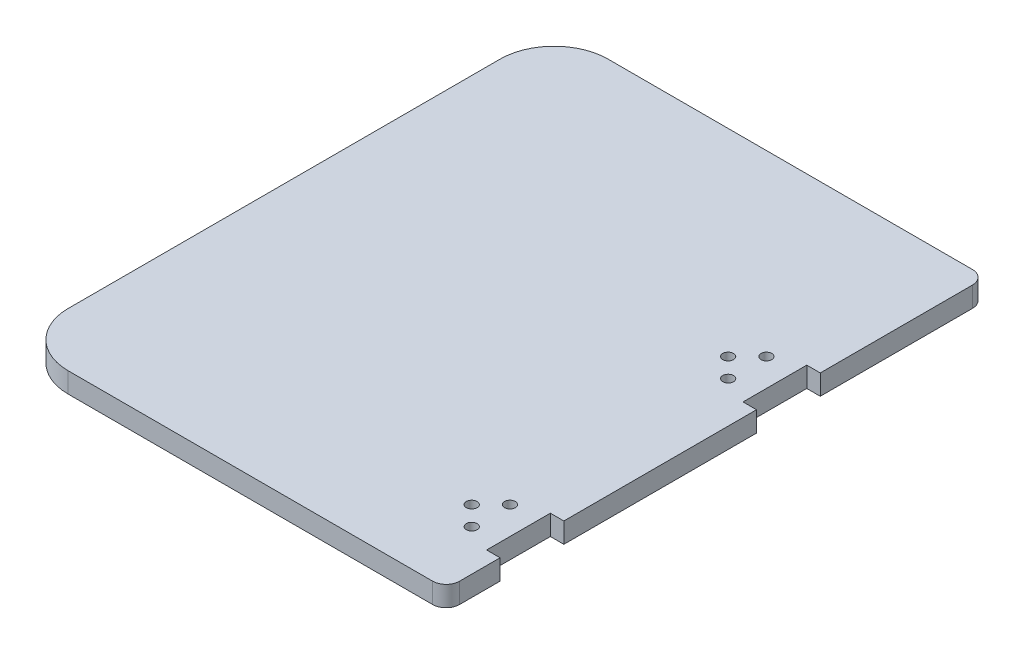
from build123d import *

# Parameters (mm, degrees)
BOSS_EXTRUDE1_DEPTH = 9.525
CUT_EXTRUDE1_REACH  = 11.525
SKETCH2_R           = 2.54
SKETCH2_W           = 6.35
SKETCH2_H           = 30


with BuildPart() as part:
    # Sketch1 → Boss-Extrude1 (new body)
    with BuildSketch(Plane(origin=(0, 0, 0), x_dir=(1, 0, 0), z_dir=(0, 1, 0))):
        with BuildLine():
            Line((25.4, 0), (196.85, 0))
            ThreePointArc((196.85, 0), (201.340128061, 1.859871939), (203.2, 6.35))
            Line((203.2, 6.35), (203.2, 247.65))
            ThreePointArc((203.2, 247.65), (201.340128061, 252.140128061), (196.85, 254))
            Line((196.85, 254), (25.4, 254))
            ThreePointArc((25.4, 254), (7.439487758, 246.560512242), (0, 228.6))
            Line((0, 228.6), (0, 25.4))
            ThreePointArc((0, 25.4), (7.439487758, 7.439487758), (25.4, 0))
        make_face()
    extrude(amount=BOSS_EXTRUDE1_DEPTH)

    # Sketch2 → Cut-Extrude1 (cut, up to next)
    with BuildSketch(Plane(origin=(0, 9.525, 0), x_dir=(1, 0, 0), z_dir=(0, 1, 0)), mode=Mode.PRIVATE) as cut_extrude1_sk1:
        with Locations((174.85000082, 40.4)):
            Circle(SKETCH2_R)
    cut_extrude1_tool1 = extrude(cut_extrude1_sk1.sketch, amount=-CUT_EXTRUDE1_REACH, mode=Mode.PRIVATE) & part.part
    add(cut_extrude1_tool1.solids().sort_by_distance((174.850001, 9.525, -40.4))[0], mode=Mode.SUBTRACT)
    # Sketch2 → Cut-Extrude1 (cut, up to next)
    with BuildSketch(Plane(origin=(0, 9.525, 0), x_dir=(1, 0, 0), z_dir=(0, 1, 0)), mode=Mode.PRIVATE) as cut_extrude1_sk2:
        with Locations((183.8500006, 49.39999978)):
            Circle(SKETCH2_R)
    cut_extrude1_tool2 = extrude(cut_extrude1_sk2.sketch, amount=-CUT_EXTRUDE1_REACH, mode=Mode.PRIVATE) & part.part
    add(cut_extrude1_tool2.solids().sort_by_distance((183.850001, 9.525, -49.4))[0], mode=Mode.SUBTRACT)
    # Sketch2 → Cut-Extrude1 (cut, up to next)
    with BuildSketch(Plane(origin=(0, 9.525, 0), x_dir=(1, 0, 0), z_dir=(0, 1, 0)), mode=Mode.PRIVATE) as cut_extrude1_sk3:
        with Locations((183.8500006, 31.40000022)):
            Circle(SKETCH2_R)
    cut_extrude1_tool3 = extrude(cut_extrude1_sk3.sketch, amount=-CUT_EXTRUDE1_REACH, mode=Mode.PRIVATE) & part.part
    add(cut_extrude1_tool3.solids().sort_by_distance((183.850001, 9.525, -31.4))[0], mode=Mode.SUBTRACT)
    # Sketch2 → Cut-Extrude1 (cut, up to next)
    with BuildSketch(Plane(origin=(0, 9.525, 0), x_dir=(1, 0, 0), z_dir=(0, 1, 0)), mode=Mode.PRIVATE) as cut_extrude1_sk4:
        with Locations((174.85000082, 161.05)):
            Circle(SKETCH2_R)
    cut_extrude1_tool4 = extrude(cut_extrude1_sk4.sketch, amount=-CUT_EXTRUDE1_REACH, mode=Mode.PRIVATE) & part.part
    add(cut_extrude1_tool4.solids().sort_by_distance((174.850001, 9.525, -161.05))[0], mode=Mode.SUBTRACT)
    # Sketch2 → Cut-Extrude1 (cut, up to next)
    with BuildSketch(Plane(origin=(0, 9.525, 0), x_dir=(1, 0, 0), z_dir=(0, 1, 0)), mode=Mode.PRIVATE) as cut_extrude1_sk5:
        with Locations((183.8500006, 170.04999978)):
            Circle(SKETCH2_R)
    cut_extrude1_tool5 = extrude(cut_extrude1_sk5.sketch, amount=-CUT_EXTRUDE1_REACH, mode=Mode.PRIVATE) & part.part
    add(cut_extrude1_tool5.solids().sort_by_distance((183.850001, 9.525, -170.05))[0], mode=Mode.SUBTRACT)
    # Sketch2 → Cut-Extrude1 (cut, up to next)
    with BuildSketch(Plane(origin=(0, 9.525, 0), x_dir=(1, 0, 0), z_dir=(0, 1, 0)), mode=Mode.PRIVATE) as cut_extrude1_sk6:
        with Locations((183.8500006, 152.05000022)):
            Circle(SKETCH2_R)
    cut_extrude1_tool6 = extrude(cut_extrude1_sk6.sketch, amount=-CUT_EXTRUDE1_REACH, mode=Mode.PRIVATE) & part.part
    add(cut_extrude1_tool6.solids().sort_by_distance((183.850001, 9.525, -152.05))[0], mode=Mode.SUBTRACT)
    # Sketch2 → Cut-Extrude1 (cut, up to next)
    with BuildSketch(Plane(origin=(0, 9.525, 0), x_dir=(1, 0, 0), z_dir=(0, 1, 0)), mode=Mode.PRIVATE) as cut_extrude1_sk7:
        with Locations((200.025, 40.4)):
            Rectangle(SKETCH2_W, SKETCH2_H)
    cut_extrude1_tool7 = extrude(cut_extrude1_sk7.sketch, amount=-CUT_EXTRUDE1_REACH, mode=Mode.PRIVATE) & part.part
    add(cut_extrude1_tool7.solids().sort_by_distance((200.025, 9.525, -40.4))[0], mode=Mode.SUBTRACT)
    # Sketch2 → Cut-Extrude1 (cut, up to next)
    with BuildSketch(Plane(origin=(0, 9.525, 0), x_dir=(1, 0, 0), z_dir=(0, 1, 0)), mode=Mode.PRIVATE) as cut_extrude1_sk8:
        with Locations((200.025, 161.05)):
            Rectangle(SKETCH2_W, SKETCH2_H)
    cut_extrude1_tool8 = extrude(cut_extrude1_sk8.sketch, amount=-CUT_EXTRUDE1_REACH, mode=Mode.PRIVATE) & part.part
    add(cut_extrude1_tool8.solids().sort_by_distance((200.025, 9.525, -161.05))[0], mode=Mode.SUBTRACT)


solid = part.part
